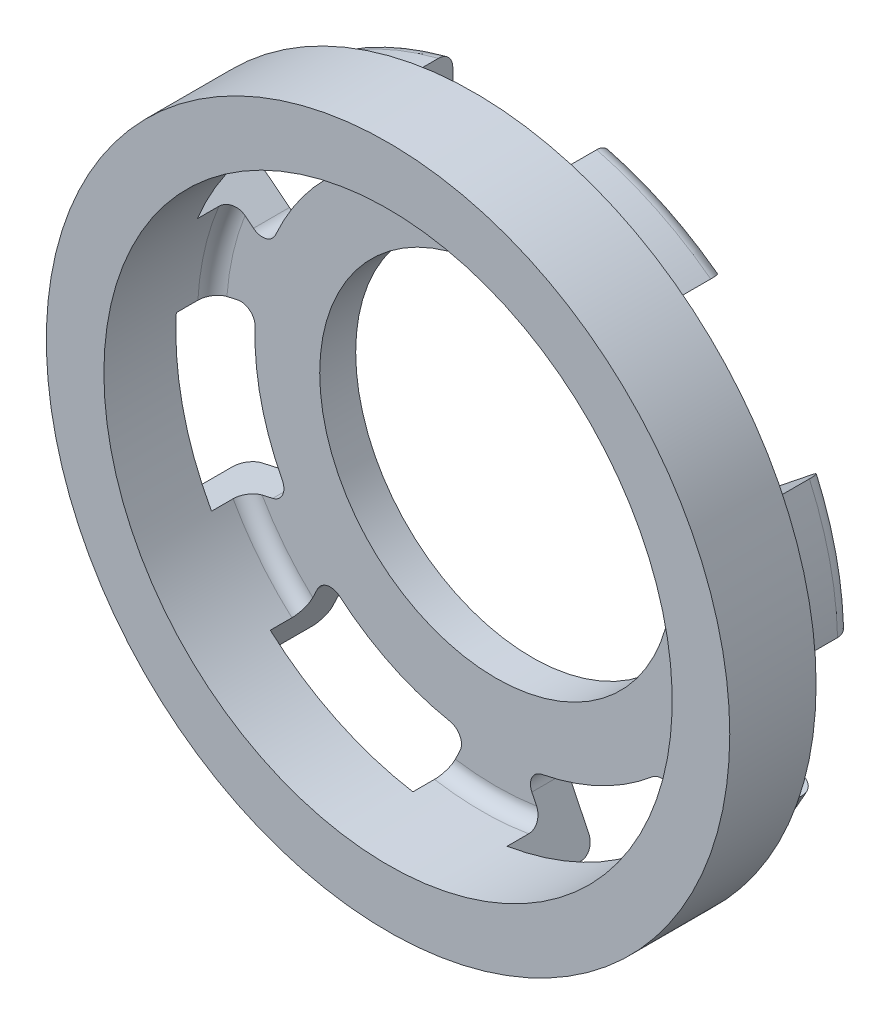
from build123d import *

# Parameters (mm, degrees)
CROQUIS1_R                 = 23.75
SALIENTE_EXTRUIR1_DEPTH    = 6
CROQUIS4_R                 = 22.25
CORTAR_EXTRUIR1_DEPTH      = 1
CROQUIS5_R                 = 19.75
CORTAR_EXTRUIR2_DEPTH      = 2
CORTAR_EXTRUIR2_DEPTH_BACK = 6
CROQUIS6_R                 = 22.25
SALIENTE_EXTRUIR2_DEPTH    = 5
CROQUIS7_R                 = 19.75
CORTAR_EXTRUIR3_DEPTH      = 2.5
REDONDEO1_R                = 1
CORTAR_EXTRUIR4_DEPTH      = 2.5
CORTAR_EXTRUIR5_DEPTH      = 2.5
MATRIZC1_COUNT             = 7
REDONDEO2_R                = 1
REDONDEO3_R                = 1
CROQUIS10_R                = 12.25
CORTAR_EXTRUIR6_DEPTH      = 1.0000001
CORTAR_EXTRUIR6_DEPTH_BACK = 11


with BuildPart() as part:
    # Croquis1 → Saliente-Extruir1 (new body)
    with BuildSketch(Plane.XY):
        Circle(CROQUIS1_R)
    extrude(amount=SALIENTE_EXTRUIR1_DEPTH)

    # Croquis4 → Cortar-Extruir1 (cut)
    with BuildSketch(Plane(origin=(0, 0, 0), x_dir=(-1, 0, 0), z_dir=(0, 0, -1))):
        Circle(CROQUIS4_R)
    extrude(amount=-CORTAR_EXTRUIR1_DEPTH, mode=Mode.SUBTRACT)

    # Croquis5 → Cortar-Extruir2 (cut, two sides)
    with BuildSketch(Plane(origin=(0, 0, 1), x_dir=(-1, 0, 0), z_dir=(0, 0, -1))) as cortar_extruir2_sk:
        Circle(CROQUIS5_R)
    extrude(amount=CORTAR_EXTRUIR2_DEPTH, mode=Mode.SUBTRACT)
    extrude(cortar_extruir2_sk.sketch, amount=-CORTAR_EXTRUIR2_DEPTH_BACK, mode=Mode.SUBTRACT)

    # Croquis6 → Saliente-Extruir2 (add)
    with BuildSketch(Plane(origin=(0, 0, 1), x_dir=(-1, 0, 0), z_dir=(0, 0, -1))):
        Circle(CROQUIS6_R)
    extrude(amount=SALIENTE_EXTRUIR2_DEPTH)

    # Croquis7 → Cortar-Extruir3 (cut)
    with BuildSketch(Plane.XY.offset(1)):
        Circle(CROQUIS7_R)
    extrude(amount=-CORTAR_EXTRUIR3_DEPTH, mode=Mode.SUBTRACT)

    # Redondeo1
    redondeo1_edges = [part.edges().sort_by_distance(p)[0] for p in [
        (-19.75, 0, -1.5),
    ]]
    fillet(redondeo1_edges, radius=REDONDEO1_R)

    # Croquis8 → Cortar-Extruir4 (cut)
    with BuildSketch(Plane(origin=(0, 0, -4), x_dir=(-1, 0, 0), z_dir=(0, 0, -1))):
        with BuildLine():
            Line((-5.5, 21.559510662), (-5.5, 15.821267332))
            ThreePointArc((-5.5, 15.821267332), (0, 16.75), (5.5, 15.821267332))
            Line((5.5, 15.821267332), (5.5, 21.559510662))
            ThreePointArc((5.5, 21.559510662), (0, 22.25), (-5.5, 21.559510662))
        make_face()
    cortar_extruir4 = extrude(amount=-CORTAR_EXTRUIR4_DEPTH, mode=Mode.SUBTRACT)

    # Croquis9 → Cortar-Extruir5 (cut)
    with BuildSketch(Plane(origin=(0, 0, -1.5), x_dir=(-1, 0, 0), z_dir=(0, 0, -1))):
        with BuildLine():
            Line((5.5, 17.92519177), (5.5, 21.559510662))
            ThreePointArc((5.5, 21.559510662), (0, 22.25), (-5.5, 21.559510662))
            Line((-5.5, 21.559510662), (-5.5, 17.92519177))
            ThreePointArc((-5.5, 17.92519177), (0, 18.75), (5.5, 17.92519177))
        make_face()
    cortar_extruir5 = extrude(amount=-CORTAR_EXTRUIR5_DEPTH, mode=Mode.SUBTRACT)

    # MatrizC1: Cortar-Extruir4, Cortar-Extruir5 ×7 about axis
    matrizc1_axis = Axis((0, 0, 0), (0, 0, 1))
    for i in range(1, MATRIZC1_COUNT):
        add(cortar_extruir4.rotate(matrizc1_axis, i * 360 / MATRIZC1_COUNT), mode=Mode.SUBTRACT)
        add(cortar_extruir5.rotate(matrizc1_axis, i * 360 / MATRIZC1_COUNT), mode=Mode.SUBTRACT)

    # Redondeo2
    redondeo2_edges = [part.edges().sort_by_distance(p)[0] for p in [
        (-14.200729992, -8.8826667, -2.75),
        (-16.648460265, 1.841540334, -2.75),
        (-1.909261854, -16.640829882, -2.75),
        (-11.819919401, -11.868108752, -2.75),
        (11.819919401, -11.868108752, -2.75),
        (1.909261854, -16.640829882, -2.75),
        (16.648460265, 1.841540334, -2.75),
        (14.200729992, -8.8826667, -2.75),
        (8.940370983, 14.164471988, -2.75),
        (15.798758803, 5.564325681, -2.75),
        (-5.5, 15.821267332, -2.75),
        (5.5, 15.821267332, -2.75),
        (-15.798758803, 5.564325681, -2.75),
        (-8.940370983, 14.164471988, -2.75),
    ]]
    fillet(redondeo2_edges, radius=REDONDEO2_R)

    # Redondeo3
    redondeo3_edges = [part.edges().sort_by_distance(p)[0] for p in [
        (9.653913195, 20.046557311, -4),
        (21.692146046, 4.951090781, -4),
        (17.395750485, -13.872648091, -4),
        (0, -22.25, -4),
        (-17.395750485, -13.872648091, -4),
        (-21.692146046, 4.951090781, -4),
        (-9.653913195, 20.046557311, -4),
    ]]
    fillet(redondeo3_edges, radius=REDONDEO3_R)

    # Croquis10 → Cortar-Extruir6 (cut, two sides)
    with BuildSketch(Plane(origin=(0, 0, -4), x_dir=(-1, 0, 0), z_dir=(0, 0, -1))) as cortar_extruir6_sk:
        Circle(CROQUIS10_R)
    extrude(amount=CORTAR_EXTRUIR6_DEPTH, mode=Mode.SUBTRACT)
    extrude(cortar_extruir6_sk.sketch, amount=-CORTAR_EXTRUIR6_DEPTH_BACK, mode=Mode.SUBTRACT)


solid = part.part
